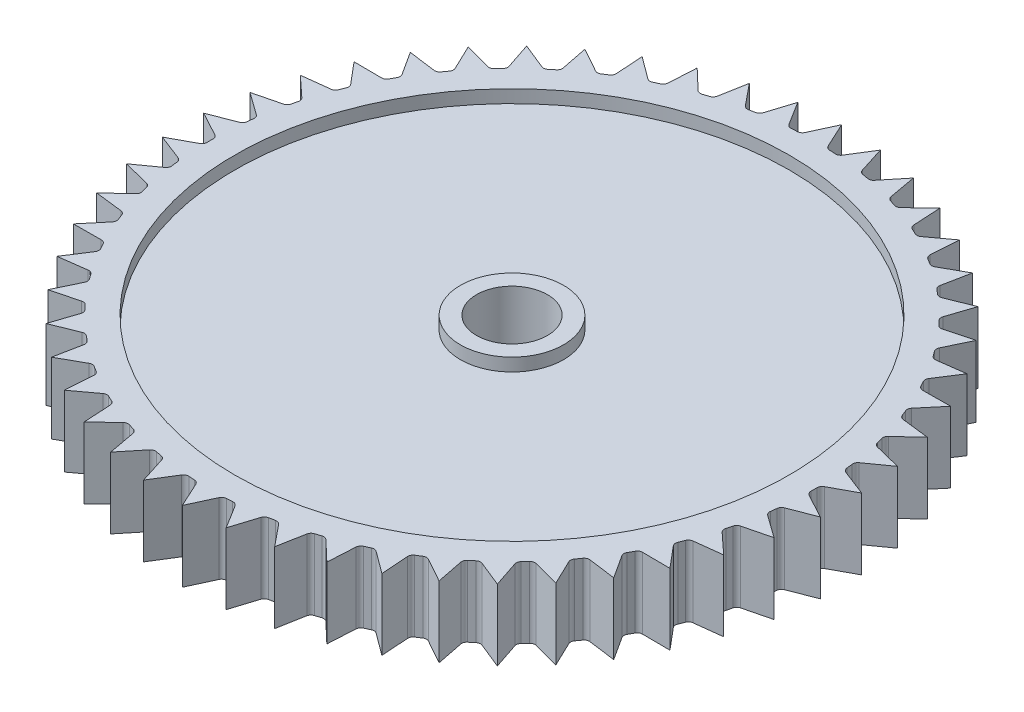
from build123d import *

# Parameters (mm, degrees)
BOSS_EXTRUDE1_DEPTH = 5.5
SKETCH2_R           = 2.75
CUT_EXTRUDE1_DEPTH  = 6.5
SKETCH3_R           = 21.5
SKETCH3_R_2         = 4
CUT_EXTRUDE2_DEPTH  = 1
SKETCH4_R           = 21.5
SKETCH4_R_2         = 4
CUT_EXTRUDE4_DEPTH  = 1


with BuildPart() as part:
    # Sketch1 → Boss-Extrude1 (new body)
    with BuildSketch(Plane(origin=(0, 0, 0), x_dir=(1, 0, 0), z_dir=(0, 1, 0))):
        with BuildLine():
            Line((0, 25.57), (-0.898312489, 23.623936741))
            ThreePointArc((-0.898312489, 23.623936741), (-1.037067197, 23.460467062), (-1.240307835, 23.392141019))
            ThreePointArc((-1.240307835, 23.392141019), (-1.47086792, 23.378776113), (-1.701285037, 23.363138792))
            ThreePointArc((-1.701285037, 23.363138792), (-1.911486585, 23.405453257), (-2.069635354, 23.550243353))
            Line((-2.069635354, 23.550243353), (-3.204770782, 25.368372913))
            Line((-3.204770782, 25.368372913), (-3.852093408, 23.325066535))
            ThreePointArc((-3.852093408, 23.325066535), (-3.96926581, 23.145495287), (-4.162340311, 23.052235209))
            ThreePointArc((-4.162340311, 23.052235209), (-4.389407294, 23.010078848), (-4.616047627, 22.96568591))
            ThreePointArc((-4.616047627, 22.96568591), (-4.829895082, 22.981321473), (-5.004943812, 23.105148559))
            Line((-5.004943812, 23.105148559), (-6.359000415, 24.76667143))
            Line((-6.359000415, 24.76667143), (-6.745124513, 22.658346095))
            ThreePointArc((-6.745124513, 22.658346095), (-6.838866731, 22.465505224), (-7.018730194, 22.348781879))
            ThreePointArc((-7.018730194, 22.348781879), (-7.238723093, 22.278498894), (-7.458012389, 22.206050441))
            ThreePointArc((-7.458012389, 22.206050441), (-7.672133249, 22.19476052), (-7.861321316, 22.295671769))
            Line((-7.861321316, 22.295671769), (-9.412944812, 23.774384744))
            Line((-9.412944812, 23.774384744), (-9.531780975, 21.634290003))
            ThreePointArc((-9.531780975, 21.634290003), (-9.600614637, 21.431220724), (-9.764430509, 21.292874908))
            ThreePointArc((-9.764430509, 21.292874908), (-9.973879905, 21.195573704), (-10.18235984, 21.096212292))
            ThreePointArc((-10.18235984, 21.096212292), (-10.393377291, 21.058174936), (-10.593721087, 21.134578917))
            Line((-10.593721087, 21.134578917), (-12.318441447, 22.407161809))
            Line((-12.318441447, 22.407161809), (-12.168115557, 20.269048233))
            ThreePointArc((-12.168115557, 20.269048233), (-12.210955116, 20.058953071), (-12.356139922, 19.901166579))
            ThreePointArc((-12.356139922, 19.901166579), (-12.551742672, 19.778381655), (-12.746125394, 19.653674273))
            ThreePointArc((-12.746125394, 19.653674273), (-12.950711564, 19.589489353), (-13.159051548, 19.640181131))
            Line((-13.159051548, 19.640181131), (-15.029668901, 20.686564546))
            Line((-15.029668901, 20.686564546), (-14.612551687, 18.584151465))
            ThreePointArc((-14.612551687, 18.584151465), (-14.628721538, 18.370343745), (-14.752985627, 18.195604966))
            ThreePointArc((-14.752985627, 18.195604966), (-14.93165696, 18.049272712), (-15.108876936, 17.90118607))
            ThreePointArc((-15.108876936, 17.90118607), (-15.30380538, 17.811865821), (-15.516855905, 17.836045955))
            Line((-15.516855905, 17.836045955), (-17.503869499, 18.639727803))
            Line((-17.503869499, 18.639727803), (-16.826539149, 16.606171526))
            ThreePointArc((-16.826539149, 16.606171526), (-16.815784282, 16.392023125), (-16.917167936, 16.203087793))
            ThreePointArc((-16.917167936, 16.203087793), (-17.076090097, 16.035515956), (-17.233352464, 15.866385469))
            ThreePointArc((-17.233352464, 15.866385469), (-17.415549043, 15.753338525), (-17.629950175, 15.75062568))
            Line((-17.629950175, 15.75062568), (-19.702023618, 16.298931418))
            Line((-19.702023618, 16.298931418), (-18.775162036, 14.366302342))
            ThreePointArc((-18.775162036, 14.366302342), (-18.737652063, 14.155190507), (-18.814556401, 13.955038246))
            ThreePointArc((-18.814556401, 13.955038246), (-18.951223093, 13.768869535), (-19.086047728, 13.581362491))
            ThreePointArc((-19.086047728, 13.581362491), (-19.252639093, 13.44637167), (-19.465009599, 13.416808629))
            Line((-19.465009599, 13.416808629), (-21.589465055, 13.701091148))
            Line((-21.589465055, 13.701091148), (-20.427689403, 11.899867988))
            ThreePointArc((-20.427689403, 11.899867988), (-20.364015878, 11.69512208), (-20.415228072, 11.486909409))
            ThreePointArc((-20.415228072, 11.486909409), (-20.52748398, 11.285079816), (-20.637744618, 11.082153314))
            ThreePointArc((-20.637744618, 11.082153314), (-20.786103525, 10.927347501), (-20.993094194, 10.871400491))
            Line((-20.993094194, 10.871400491), (-23.136427732, 10.887176485))
            Line((-23.136427732, 10.887176485), (-21.758059904, 9.245765608))
            ThreePointArc((-21.758059904, 9.245765608), (-21.669226998, 9.05061459), (-21.693939401, 8.837625149))
            ThreePointArc((-21.693939401, 8.837625149), (-21.780014182, 8.623317647), (-21.863971947, 8.408171958))
            ThreePointArc((-21.863971947, 8.408171958), (-21.991758687, 8.235992534), (-22.190105153, 8.154543873))
            Line((-22.190105153, 8.154543873), (-24.318515122, 7.901564546))
            Line((-24.318515122, 7.901564546), (-22.745292804, 6.445851981))
            ThreePointArc((-22.745292804, 6.445851981), (-22.632701463, 6.263373503), (-22.630524346, 6.048966261))
            ThreePointArc((-22.630524346, 6.048966261), (-22.689060549, 5.825560607), (-22.745391378, 5.601588708))
            ThreePointArc((-22.745391378, 5.601588708), (-22.850590677, 5.414751045), (-23.037164898, 5.309085227))
            Line((-23.037164898, 5.309085227), (-25.117085001, 4.791340214))
            Line((-25.117085001, 4.791340214), (-23.373818848, 3.544283417))
            ThreePointArc((-23.373818848, 3.544283417), (-23.239244706, 3.377355273), (-23.210212403, 3.164911562))
            ThreePointArc((-23.210212403, 3.164911562), (-23.240286878, 2.935930996), (-23.268102399, 2.706665058))
            ThreePointArc((-23.268102399, 2.706665058), (-23.349055201, 2.508115697), (-23.52091479, 2.379899136))
            Line((-23.52091479, 2.379899136), (-25.519543446, 1.605553584))
            Line((-25.519543446, 1.605553584), (-23.633725806, 0.586819387))
            ThreePointArc((-23.633725806, 0.586819387), (-23.479291178, 0.438074133), (-23.423861546, 0.230944317))
            ThreePointArc((-23.423861546, 0.230944317), (-23.425, 0), (-23.423861546, -0.230944317))
            ThreePointArc((-23.423861546, -0.230944317), (-23.479291178, -0.438074133), (-23.633725806, -0.586819387))
            Line((-23.633725806, -0.586819387), (-25.519543446, -1.605553584))
            Line((-25.519543446, -1.605553584), (-23.52091479, -2.379899136))
            ThreePointArc((-23.52091479, -2.379899136), (-23.349055201, -2.508115697), (-23.268102399, -2.706665058))
            ThreePointArc((-23.268102399, -2.706665058), (-23.240286878, -2.935930996), (-23.210212403, -3.164911562))
            ThreePointArc((-23.210212403, -3.164911562), (-23.239244706, -3.377355273), (-23.373818848, -3.544283417))
            Line((-23.373818848, -3.544283417), (-25.117085001, -4.791340214))
            Line((-25.117085001, -4.791340214), (-23.037164898, -5.309085227))
            ThreePointArc((-23.037164898, -5.309085227), (-22.850590677, -5.414751045), (-22.745391378, -5.601588708))
            ThreePointArc((-22.745391378, -5.601588708), (-22.689060549, -5.825560607), (-22.630524346, -6.048966261))
            ThreePointArc((-22.630524346, -6.048966261), (-22.632701463, -6.263373503), (-22.745292804, -6.445851981))
            Line((-22.745292804, -6.445851981), (-24.318515122, -7.901564546))
            Line((-24.318515122, -7.901564546), (-22.190105153, -8.154543873))
            ThreePointArc((-22.190105153, -8.154543873), (-21.991758687, -8.235992534), (-21.863971947, -8.408171958))
            ThreePointArc((-21.863971947, -8.408171958), (-21.780014182, -8.623317647), (-21.693939401, -8.837625149))
            ThreePointArc((-21.693939401, -8.837625149), (-21.669226998, -9.05061459), (-21.758059904, -9.245765608))
            Line((-21.758059904, -9.245765608), (-23.136427732, -10.887176485))
            Line((-23.136427732, -10.887176485), (-20.993094194, -10.871400491))
            ThreePointArc((-20.993094194, -10.871400491), (-20.786103525, -10.927347501), (-20.637744618, -11.082153314))
            ThreePointArc((-20.637744618, -11.082153314), (-20.52748398, -11.285079816), (-20.415228072, -11.486909409))
            ThreePointArc((-20.415228072, -11.486909409), (-20.364015878, -11.69512208), (-20.427689403, -11.899867988))
            Line((-20.427689403, -11.899867988), (-21.589465055, -13.701091148))
            Line((-21.589465055, -13.701091148), (-19.465009599, -13.416808629))
            ThreePointArc((-19.465009599, -13.416808629), (-19.252639093, -13.44637167), (-19.086047728, -13.581362491))
            ThreePointArc((-19.086047728, -13.581362491), (-18.951223093, -13.768869535), (-18.814556401, -13.955038246))
            ThreePointArc((-18.814556401, -13.955038246), (-18.737652063, -14.155190507), (-18.775162036, -14.366302342))
            Line((-18.775162036, -14.366302342), (-19.702023618, -16.298931418))
            Line((-19.702023618, -16.298931418), (-17.629950175, -15.75062568))
            ThreePointArc((-17.629950175, -15.75062568), (-17.415549043, -15.753338525), (-17.233352464, -15.866385469))
            ThreePointArc((-17.233352464, -15.866385469), (-17.076090097, -16.035515956), (-16.917167936, -16.203087793))
            ThreePointArc((-16.917167936, -16.203087793), (-16.815784282, -16.392023125), (-16.826539149, -16.606171526))
            Line((-16.826539149, -16.606171526), (-17.503869499, -18.639727803))
            Line((-17.503869499, -18.639727803), (-15.516855905, -17.836045955))
            ThreePointArc((-15.516855905, -17.836045955), (-15.30380538, -17.811865821), (-15.108876936, -17.90118607))
            ThreePointArc((-15.108876936, -17.90118607), (-14.93165696, -18.049272712), (-14.752985627, -18.195604966))
            ThreePointArc((-14.752985627, -18.195604966), (-14.628721538, -18.370343745), (-14.612551687, -18.584151465))
            Line((-14.612551687, -18.584151465), (-15.029668901, -20.686564546))
            Line((-15.029668901, -20.686564546), (-13.159051548, -19.640181131))
            ThreePointArc((-13.159051548, -19.640181131), (-12.950711564, -19.589489353), (-12.746125394, -19.653674273))
            ThreePointArc((-12.746125394, -19.653674273), (-12.551742672, -19.778381655), (-12.356139922, -19.901166579))
            ThreePointArc((-12.356139922, -19.901166579), (-12.210955116, -20.058953071), (-12.168115557, -20.269048233))
            Line((-12.168115557, -20.269048233), (-12.318441447, -22.407161809))
            Line((-12.318441447, -22.407161809), (-10.593721087, -21.134578917))
            ThreePointArc((-10.593721087, -21.134578917), (-10.393377291, -21.058174936), (-10.18235984, -21.096212292))
            ThreePointArc((-10.18235984, -21.096212292), (-9.973879905, -21.195573704), (-9.764430509, -21.292874908))
            ThreePointArc((-9.764430509, -21.292874908), (-9.600614637, -21.431220724), (-9.531780975, -21.634290003))
            Line((-9.531780975, -21.634290003), (-9.412944812, -23.774384744))
            Line((-9.412944812, -23.774384744), (-7.861321316, -22.295671769))
            ThreePointArc((-7.861321316, -22.295671769), (-7.672133249, -22.19476052), (-7.458012389, -22.206050441))
            ThreePointArc((-7.458012389, -22.206050441), (-7.238723093, -22.278498894), (-7.018730194, -22.348781879))
            ThreePointArc((-7.018730194, -22.348781879), (-6.838866731, -22.465505224), (-6.745124513, -22.658346095))
            Line((-6.745124513, -22.658346095), (-6.359000415, -24.76667143))
            Line((-6.359000415, -24.76667143), (-5.004943812, -23.105148559))
            ThreePointArc((-5.004943812, -23.105148559), (-4.829895082, -22.981321473), (-4.616047627, -22.96568591))
            ThreePointArc((-4.616047627, -22.96568591), (-4.389407294, -23.010078848), (-4.162340311, -23.052235209))
            ThreePointArc((-4.162340311, -23.052235209), (-3.96926581, -23.145495287), (-3.852093408, -23.325066535))
            Line((-3.852093408, -23.325066535), (-3.204770782, -25.368372913))
            Line((-3.204770782, -25.368372913), (-2.069635354, -23.550243353))
            ThreePointArc((-2.069635354, -23.550243353), (-1.911486585, -23.405453257), (-1.701285037, -23.363138792))
            ThreePointArc((-1.701285037, -23.363138792), (-1.47086792, -23.378776113), (-1.240307835, -23.392141019))
            ThreePointArc((-1.240307835, -23.392141019), (-1.037067197, -23.460467062), (-0.898312489, -23.623936741))
            Line((-0.898312489, -23.623936741), (0, -25.57))
            Line((0, -25.57), (0.898312489, -23.623936741))
            ThreePointArc((0.898312489, -23.623936741), (1.037067197, -23.460467062), (1.240307835, -23.392141019))
            ThreePointArc((1.240307835, -23.392141019), (1.47086792, -23.378776113), (1.701285037, -23.363138792))
            ThreePointArc((1.701285037, -23.363138792), (1.911486585, -23.405453257), (2.069635354, -23.550243353))
            Line((2.069635354, -23.550243353), (3.204770782, -25.368372913))
            Line((3.204770782, -25.368372913), (3.852093408, -23.325066535))
            ThreePointArc((3.852093408, -23.325066535), (3.96926581, -23.145495287), (4.162340311, -23.052235209))
            ThreePointArc((4.162340311, -23.052235209), (4.389407294, -23.010078848), (4.616047627, -22.96568591))
            ThreePointArc((4.616047627, -22.96568591), (4.829895082, -22.981321473), (5.004943812, -23.105148559))
            Line((5.004943812, -23.105148559), (6.359000415, -24.76667143))
            Line((6.359000415, -24.76667143), (6.745124513, -22.658346095))
            ThreePointArc((6.745124513, -22.658346095), (6.838866731, -22.465505224), (7.018730194, -22.348781879))
            ThreePointArc((7.018730194, -22.348781879), (7.238723093, -22.278498894), (7.458012389, -22.206050441))
            ThreePointArc((7.458012389, -22.206050441), (7.672133249, -22.19476052), (7.861321316, -22.295671769))
            Line((7.861321316, -22.295671769), (9.412944812, -23.774384744))
            Line((9.412944812, -23.774384744), (9.531780975, -21.634290003))
            ThreePointArc((9.531780975, -21.634290003), (9.600614637, -21.431220724), (9.764430509, -21.292874908))
            ThreePointArc((9.764430509, -21.292874908), (9.973879905, -21.195573704), (10.18235984, -21.096212292))
            ThreePointArc((10.18235984, -21.096212292), (10.393377291, -21.058174936), (10.593721087, -21.134578917))
            Line((10.593721087, -21.134578917), (12.318441447, -22.407161809))
            Line((12.318441447, -22.407161809), (12.168115557, -20.269048233))
            ThreePointArc((12.168115557, -20.269048233), (12.210955116, -20.058953071), (12.356139922, -19.901166579))
            ThreePointArc((12.356139922, -19.901166579), (12.551742672, -19.778381655), (12.746125394, -19.653674273))
            ThreePointArc((12.746125394, -19.653674273), (12.950711564, -19.589489353), (13.159051548, -19.640181131))
            Line((13.159051548, -19.640181131), (15.029668901, -20.686564546))
            Line((15.029668901, -20.686564546), (14.612551687, -18.584151465))
            ThreePointArc((14.612551687, -18.584151465), (14.628721538, -18.370343745), (14.752985627, -18.195604966))
            ThreePointArc((14.752985627, -18.195604966), (14.93165696, -18.049272712), (15.108876936, -17.90118607))
            ThreePointArc((15.108876936, -17.90118607), (15.30380538, -17.811865821), (15.516855905, -17.836045955))
            Line((15.516855905, -17.836045955), (17.503869499, -18.639727803))
            Line((17.503869499, -18.639727803), (16.826539149, -16.606171526))
            ThreePointArc((16.826539149, -16.606171526), (16.815784282, -16.392023125), (16.917167936, -16.203087793))
            ThreePointArc((16.917167936, -16.203087793), (17.076090097, -16.035515956), (17.233352464, -15.866385469))
            ThreePointArc((17.233352464, -15.866385469), (17.415549043, -15.753338525), (17.629950175, -15.75062568))
            Line((17.629950175, -15.75062568), (19.702023618, -16.298931418))
            Line((19.702023618, -16.298931418), (18.775162036, -14.366302342))
            ThreePointArc((18.775162036, -14.366302342), (18.737652063, -14.155190507), (18.814556401, -13.955038246))
            ThreePointArc((18.814556401, -13.955038246), (18.951223093, -13.768869535), (19.086047728, -13.581362491))
            ThreePointArc((19.086047728, -13.581362491), (19.252639093, -13.44637167), (19.465009599, -13.416808629))
            Line((19.465009599, -13.416808629), (21.589465055, -13.701091148))
            Line((21.589465055, -13.701091148), (20.427689403, -11.899867988))
            ThreePointArc((20.427689403, -11.899867988), (20.364015878, -11.69512208), (20.415228072, -11.486909409))
            ThreePointArc((20.415228072, -11.486909409), (20.52748398, -11.285079816), (20.637744618, -11.082153314))
            ThreePointArc((20.637744618, -11.082153314), (20.786103525, -10.927347501), (20.993094194, -10.871400491))
            Line((20.993094194, -10.871400491), (23.136427732, -10.887176485))
            Line((23.136427732, -10.887176485), (21.758059904, -9.245765608))
            ThreePointArc((21.758059904, -9.245765608), (21.669226998, -9.05061459), (21.693939401, -8.837625149))
            ThreePointArc((21.693939401, -8.837625149), (21.780014182, -8.623317647), (21.863971947, -8.408171958))
            ThreePointArc((21.863971947, -8.408171958), (21.991758687, -8.235992534), (22.190105153, -8.154543873))
            Line((22.190105153, -8.154543873), (24.318515122, -7.901564546))
            Line((24.318515122, -7.901564546), (22.745292804, -6.445851981))
            ThreePointArc((22.745292804, -6.445851981), (22.632701463, -6.263373503), (22.630524346, -6.048966261))
            ThreePointArc((22.630524346, -6.048966261), (22.689060549, -5.825560607), (22.745391378, -5.601588708))
            ThreePointArc((22.745391378, -5.601588708), (22.850590677, -5.414751045), (23.037164898, -5.309085227))
            Line((23.037164898, -5.309085227), (25.117085001, -4.791340214))
            Line((25.117085001, -4.791340214), (23.373818848, -3.544283417))
            ThreePointArc((23.373818848, -3.544283417), (23.239244706, -3.377355273), (23.210212403, -3.164911562))
            ThreePointArc((23.210212403, -3.164911562), (23.240286878, -2.935930996), (23.268102399, -2.706665058))
            ThreePointArc((23.268102399, -2.706665058), (23.349055201, -2.508115697), (23.52091479, -2.379899136))
            Line((23.52091479, -2.379899136), (25.519543446, -1.605553584))
            Line((25.519543446, -1.605553584), (23.633725806, -0.586819387))
            ThreePointArc((23.633725806, -0.586819387), (23.479291178, -0.438074133), (23.423861546, -0.230944317))
            ThreePointArc((23.423861546, -0.230944317), (23.425, 0), (23.423861546, 0.230944317))
            ThreePointArc((23.423861546, 0.230944317), (23.479291178, 0.438074133), (23.633725806, 0.586819387))
            Line((23.633725806, 0.586819387), (25.519543446, 1.605553584))
            Line((25.519543446, 1.605553584), (23.52091479, 2.379899136))
            ThreePointArc((23.52091479, 2.379899136), (23.349055201, 2.508115697), (23.268102399, 2.706665058))
            ThreePointArc((23.268102399, 2.706665058), (23.240286878, 2.935930996), (23.210212403, 3.164911562))
            ThreePointArc((23.210212403, 3.164911562), (23.239244706, 3.377355273), (23.373818848, 3.544283417))
            Line((23.373818848, 3.544283417), (25.117085001, 4.791340214))
            Line((25.117085001, 4.791340214), (23.037164898, 5.309085227))
            ThreePointArc((23.037164898, 5.309085227), (22.850590677, 5.414751045), (22.745391378, 5.601588708))
            ThreePointArc((22.745391378, 5.601588708), (22.689060549, 5.825560607), (22.630524346, 6.048966261))
            ThreePointArc((22.630524346, 6.048966261), (22.632701463, 6.263373503), (22.745292804, 6.445851981))
            Line((22.745292804, 6.445851981), (24.318515122, 7.901564546))
            Line((24.318515122, 7.901564546), (22.190105153, 8.154543873))
            ThreePointArc((22.190105153, 8.154543873), (21.991758687, 8.235992534), (21.863971947, 8.408171958))
            ThreePointArc((21.863971947, 8.408171958), (21.780014182, 8.623317647), (21.693939401, 8.837625149))
            ThreePointArc((21.693939401, 8.837625149), (21.669226998, 9.05061459), (21.758059904, 9.245765608))
            Line((21.758059904, 9.245765608), (23.136427732, 10.887176485))
            Line((23.136427732, 10.887176485), (20.993094194, 10.871400491))
            ThreePointArc((20.993094194, 10.871400491), (20.786103525, 10.927347501), (20.637744618, 11.082153314))
            ThreePointArc((20.637744618, 11.082153314), (20.52748398, 11.285079816), (20.415228072, 11.486909409))
            ThreePointArc((20.415228072, 11.486909409), (20.364015878, 11.69512208), (20.427689403, 11.899867988))
            Line((20.427689403, 11.899867988), (21.589465055, 13.701091148))
            Line((21.589465055, 13.701091148), (19.465009599, 13.416808629))
            ThreePointArc((19.465009599, 13.416808629), (19.252639093, 13.44637167), (19.086047728, 13.581362491))
            ThreePointArc((19.086047728, 13.581362491), (18.951223093, 13.768869535), (18.814556401, 13.955038246))
            ThreePointArc((18.814556401, 13.955038246), (18.737652063, 14.155190507), (18.775162036, 14.366302342))
            Line((18.775162036, 14.366302342), (19.702023618, 16.298931418))
            Line((19.702023618, 16.298931418), (17.629950175, 15.75062568))
            ThreePointArc((17.629950175, 15.75062568), (17.415549043, 15.753338525), (17.233352464, 15.866385469))
            ThreePointArc((17.233352464, 15.866385469), (17.076090097, 16.035515956), (16.917167936, 16.203087793))
            ThreePointArc((16.917167936, 16.203087793), (16.815784282, 16.392023125), (16.826539149, 16.606171526))
            Line((16.826539149, 16.606171526), (17.503869499, 18.639727803))
            Line((17.503869499, 18.639727803), (15.516855905, 17.836045955))
            ThreePointArc((15.516855905, 17.836045955), (15.30380538, 17.811865821), (15.108876936, 17.90118607))
            ThreePointArc((15.108876936, 17.90118607), (14.93165696, 18.049272712), (14.752985627, 18.195604966))
            ThreePointArc((14.752985627, 18.195604966), (14.628721538, 18.370343745), (14.612551687, 18.584151465))
            Line((14.612551687, 18.584151465), (15.029668901, 20.686564546))
            Line((15.029668901, 20.686564546), (13.159051548, 19.640181131))
            ThreePointArc((13.159051548, 19.640181131), (12.950711564, 19.589489353), (12.746125394, 19.653674273))
            ThreePointArc((12.746125394, 19.653674273), (12.551742672, 19.778381655), (12.356139922, 19.901166579))
            ThreePointArc((12.356139922, 19.901166579), (12.210955116, 20.058953071), (12.168115557, 20.269048233))
            Line((12.168115557, 20.269048233), (12.318441447, 22.407161809))
            Line((12.318441447, 22.407161809), (10.593721087, 21.134578917))
            ThreePointArc((10.593721087, 21.134578917), (10.393377291, 21.058174936), (10.18235984, 21.096212292))
            ThreePointArc((10.18235984, 21.096212292), (9.973879905, 21.195573704), (9.764430509, 21.292874908))
            ThreePointArc((9.764430509, 21.292874908), (9.600614637, 21.431220724), (9.531780975, 21.634290003))
            Line((9.531780975, 21.634290003), (9.412944812, 23.774384744))
            Line((9.412944812, 23.774384744), (7.861321316, 22.295671769))
            ThreePointArc((7.861321316, 22.295671769), (7.672133249, 22.19476052), (7.458012389, 22.206050441))
            ThreePointArc((7.458012389, 22.206050441), (7.238723093, 22.278498894), (7.018730194, 22.348781879))
            ThreePointArc((7.018730194, 22.348781879), (6.838866731, 22.465505224), (6.745124513, 22.658346095))
            Line((6.745124513, 22.658346095), (6.359000415, 24.76667143))
            Line((6.359000415, 24.76667143), (5.004943812, 23.105148559))
            ThreePointArc((5.004943812, 23.105148559), (4.829895082, 22.981321473), (4.616047627, 22.96568591))
            ThreePointArc((4.616047627, 22.96568591), (4.389407294, 23.010078848), (4.162340311, 23.052235209))
            ThreePointArc((4.162340311, 23.052235209), (3.96926581, 23.145495287), (3.852093408, 23.325066535))
            Line((3.852093408, 23.325066535), (3.204770782, 25.368372913))
            Line((3.204770782, 25.368372913), (2.069635354, 23.550243353))
            ThreePointArc((2.069635354, 23.550243353), (1.911486585, 23.405453257), (1.701285037, 23.363138792))
            ThreePointArc((1.701285037, 23.363138792), (1.47086792, 23.378776113), (1.240307835, 23.392141019))
            ThreePointArc((1.240307835, 23.392141019), (1.037067197, 23.460467062), (0.898312489, 23.623936741))
            Line((0.898312489, 23.623936741), (0, 25.57))
        make_face()
    extrude(amount=BOSS_EXTRUDE1_DEPTH)

    # Sketch2 → Cut-Extrude1 (cut, through all)
    with BuildSketch(Plane(origin=(0, 5.5, 0), x_dir=(1, 0, 0), z_dir=(0, 1, 0))):
        Circle(SKETCH2_R)
    extrude(amount=-CUT_EXTRUDE1_DEPTH, mode=Mode.SUBTRACT)

    # Sketch3 → Cut-Extrude2 (cut)
    with BuildSketch(Plane(origin=(0, 5.5, 0), x_dir=(1, 0, 0), z_dir=(0, 1, 0))):
        Circle(SKETCH3_R)
        Circle(SKETCH3_R_2, mode=Mode.SUBTRACT)
    extrude(amount=-CUT_EXTRUDE2_DEPTH, mode=Mode.SUBTRACT)

    # Sketch4 → Cut-Extrude4 (cut)
    with BuildSketch(Plane.XZ):
        Circle(SKETCH4_R)
        Circle(SKETCH4_R_2, mode=Mode.SUBTRACT)
    extrude(amount=-CUT_EXTRUDE4_DEPTH, mode=Mode.SUBTRACT)


solid = part.part
